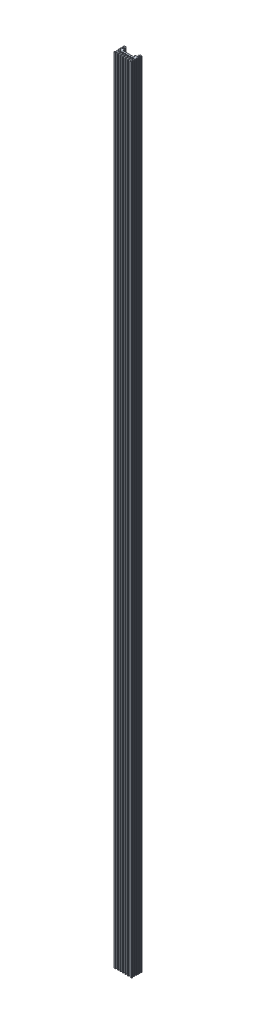
from build123d import *

# Parameters (mm, degrees)
SALIENTE_EXTRUIR1_DEPTH = 920


with BuildPart() as part:
    # Croquis1 → Saliente-Extruir1 (new body)
    with BuildSketch(Plane(origin=(0, 0, 0), x_dir=(1, 0, 0), z_dir=(0, 1, 0))):
        with BuildLine():
            Line((-12.795818551, 0), (-12.344725918, 0))
            ThreePointArc((-12.344725918, 0), (-12.164799993, 0.074527758), (-12.090272234, 0.254453684))
            Line((-12.090272234, 0.254453684), (-12.090272234, 4.705546316))
            ThreePointArc((-12.090272234, 4.705546316), (-12.015744476, 4.885472242), (-11.835818551, 4.96))
            Line((-11.835818551, 4.96), (-10.424725918, 4.96))
            ThreePointArc((-10.424725918, 4.96), (-10.244799993, 4.885472242), (-10.170272234, 4.705546316))
            Line((-10.170272234, 4.705546316), (-10.170272234, 0.254453684))
            ThreePointArc((-10.170272234, 0.254453684), (-10.095744476, 0.074527758), (-9.915818551, 0))
            Line((-9.915818551, 0), (-9.464725918, 0))
            ThreePointArc((-9.464725918, 0), (-9.284799993, 0.074527758), (-9.210272234, 0.254453684))
            Line((-9.210272234, 0.254453684), (-9.210272234, 4.705546316))
            ThreePointArc((-9.210272234, 4.705546316), (-9.135744476, 4.885472242), (-8.955818551, 4.96))
            Line((-8.955818551, 4.96), (-7.544725918, 4.96))
            ThreePointArc((-7.544725918, 4.96), (-7.364799993, 4.885472242), (-7.290272234, 4.705546316))
            Line((-7.290272234, 4.705546316), (-7.290272234, 0.254453684))
            ThreePointArc((-7.290272234, 0.254453684), (-7.215744476, 0.074527758), (-7.035818551, 0))
            Line((-7.035818551, 0), (-6.584725918, 0))
            ThreePointArc((-6.584725918, 0), (-6.404799993, 0.074527758), (-6.330272234, 0.254453684))
            Line((-6.330272234, 0.254453684), (-6.330272234, 4.705546316))
            ThreePointArc((-6.330272234, 4.705546316), (-6.255744476, 4.885472242), (-6.075818551, 4.96))
            Line((-6.075818551, 4.96), (-4.664725918, 4.96))
            ThreePointArc((-4.664725918, 4.96), (-4.484799993, 4.885472242), (-4.410272234, 4.705546316))
            Line((-4.410272234, 4.705546316), (-4.410272234, 0.254453684))
            ThreePointArc((-4.410272234, 0.254453684), (-4.335744476, 0.074527758), (-4.155818551, 0))
            Line((-4.155818551, 0), (-3.704725918, 0))
            ThreePointArc((-3.704725918, 0), (-3.524799993, 0.074527758), (-3.450272234, 0.254453684))
            Line((-3.450272234, 0.254453684), (-3.450272234, 4.705546316))
            ThreePointArc((-3.450272234, 4.705546316), (-3.375744476, 4.885472242), (-3.195818551, 4.96))
            Line((-3.195818551, 4.96), (-1.784725918, 4.96))
            ThreePointArc((-1.784725918, 4.96), (-1.604799993, 4.885472242), (-1.530272234, 4.705546316))
            Line((-1.530272234, 4.705546316), (-1.530272234, 0.254453684))
            ThreePointArc((-1.530272234, 0.254453684), (-1.455744476, 0.074527758), (-1.275818551, 0))
            Line((-1.275818551, 0), (-0.824725918, 0))
            ThreePointArc((-0.824725918, 0), (-0.644799993, 0.074527758), (-0.570272234, 0.254453684))
            Line((-0.570272234, 0.254453684), (-0.570272234, 4.705546316))
            ThreePointArc((-0.570272234, 4.705546316), (-0.495744476, 4.885472242), (-0.315818551, 4.96))
            Line((-0.315818551, 4.96), (1.095274082, 4.96))
            ThreePointArc((1.095274082, 4.96), (1.275200007, 4.885472242), (1.349727766, 4.705546316))
            Line((1.349727766, 4.705546316), (1.349727766, 0.3))
            ThreePointArc((1.349727766, 0.3), (1.437595731, 0.087867966), (1.649727766, 0))
            Line((1.649727766, 0), (3.175274082, 0))
            ThreePointArc((3.175274082, 0), (3.355200007, 0.074527758), (3.429727766, 0.254453684))
            Line((3.429727766, 0.254453684), (3.429727766, 0.705546316))
            ThreePointArc((3.429727766, 0.705546316), (3.355200007, 0.885472242), (3.175274082, 0.96))
            Line((3.175274082, 0.96), (2.724181449, 0.96))
            ThreePointArc((2.724181449, 0.96), (2.544255524, 1.034527758), (2.469727766, 1.214453684))
            Line((2.469727766, 1.214453684), (2.469727766, 2.305546316))
            ThreePointArc((2.469727766, 2.305546316), (2.544255524, 2.485472242), (2.724181449, 2.56))
            Line((2.724181449, 2.56), (3.175274082, 2.56))
            ThreePointArc((3.175274082, 2.56), (3.355200007, 2.634527758), (3.429727766, 2.814453684))
            Line((3.429727766, 2.814453684), (3.429727766, 3.265546316))
            ThreePointArc((3.429727766, 3.265546316), (3.355200007, 3.445472242), (3.175274082, 3.52))
            Line((3.175274082, 3.52), (2.724181449, 3.52))
            ThreePointArc((2.724181449, 3.52), (2.544255524, 3.594527758), (2.469727766, 3.774453684))
            Line((2.469727766, 3.774453684), (2.469727766, 4.705546316))
            ThreePointArc((2.469727766, 4.705546316), (2.544255524, 4.885472242), (2.724181449, 4.96))
            Line((2.724181449, 4.96), (3.175274082, 4.96))
            ThreePointArc((3.175274082, 4.96), (3.355200007, 5.034527758), (3.429727766, 5.214453684))
            Line((3.429727766, 5.214453684), (3.429727766, 5.799468719))
            ThreePointArc((3.429727766, 5.799468719), (3.397938251, 5.922624495), (3.310512788, 6.015007972))
            ThreePointArc((3.310512788, 6.015007972), (2.8735065, 6.114529702), (2.469727766, 5.92))
            ThreePointArc((2.469727766, 5.92), (1.869727766, 6.52), (2.469727766, 7.12))
            ThreePointArc((2.469727766, 7.12), (2.902206504, 6.922842906), (3.357982704, 7.057664398))
            ThreePointArc((3.357982704, 7.057664398), (3.410795902, 7.121117035), (3.429727766, 7.201472841))
            Line((3.429727766, 7.201472841), (3.429727766, 7.9))
            ThreePointArc((3.429727766, 7.9), (3.377006986, 8.027279221), (3.249727766, 8.08))
            Line((3.249727766, 8.08), (2.011728335, 8.08))
            ThreePointArc((2.011728335, 8.08), (1.884449114, 8.132720779), (1.831728335, 8.26))
            Line((1.831728335, 8.26), (1.831728335, 8.66))
            ThreePointArc((1.831728335, 8.66), (1.884449114, 8.787279221), (2.011728335, 8.84))
            Line((2.011728335, 8.84), (3.249727766, 8.84))
            ThreePointArc((3.249727766, 8.84), (3.377006986, 8.892720779), (3.429727766, 9.02))
            Line((3.429727766, 9.02), (3.429727766, 9.62))
            ThreePointArc((3.429727766, 9.62), (3.377006986, 9.747279221), (3.249727766, 9.8))
            Line((3.249727766, 9.8), (2.011728335, 9.8))
            ThreePointArc((2.011728335, 9.8), (1.884449114, 9.852720779), (1.831728335, 9.98))
            Line((1.831728335, 9.98), (1.831728335, 10.58))
            ThreePointArc((1.831728335, 10.58), (1.884449114, 10.707279221), (2.011728335, 10.76))
            Line((2.011728335, 10.76), (3.249727766, 10.76))
            ThreePointArc((3.249727766, 10.76), (3.377006986, 10.812720779), (3.429727766, 10.94))
            Line((3.429727766, 10.94), (3.429727766, 11.582241708))
            ThreePointArc((3.429727766, 11.582241708), (3.392572396, 11.691765274), (3.296445415, 11.756073411))
            ThreePointArc((3.296445415, 11.756073411), (2.405656106, 11.98423262), (1.509727766, 12.191294507))
            ThreePointArc((1.509727766, 12.191294507), (1.442603785, 11.578123194), (0.927709131, 11.238464272))
            ThreePointArc((0.927709131, 11.238464272), (0.77179227, 11.15317057), (0.709727766, 10.986638048))
            Line((0.709727766, 10.986638048), (0.709727766, 9.904615947))
            ThreePointArc((0.709727766, 9.904615947), (0.77079599, 9.739241399), (0.924688231, 9.653245776))
            ThreePointArc((0.924688231, 9.653245776), (1.337381638, 9.065066234), (0.734940069, 8.673485873))
            ThreePointArc((0.734940069, 8.673485873), (0.706521357, 8.678366223), (0.677732961, 8.68))
            Line((0.677732961, 8.68), (-1.246608635, 8.68))
            ThreePointArc((-1.246608635, 8.68), (-1.369764411, 8.648210485), (-1.462147888, 8.560785023))
            ThreePointArc((-1.462147888, 8.560785023), (-1.565962426, 8.2), (-1.462147888, 7.839214977))
            ThreePointArc((-1.462147888, 7.839214977), (-1.369764411, 7.751789515), (-1.246608635, 7.72))
            Line((-1.246608635, 7.72), (-0.68264527, 7.72))
            ThreePointArc((-0.68264527, 7.72), (-0.568471526, 7.692946917), (-0.478575298, 7.617540144))
            ThreePointArc((-0.478575298, 7.617540144), (-0.293758965, 7.06), (-0.478575298, 6.502459856))
            ThreePointArc((-0.478575298, 6.502459856), (-0.568471526, 6.427053083), (-0.68264527, 6.4))
            Line((-0.68264527, 6.4), (-12.937899199, 6.4))
            ThreePointArc((-12.937899199, 6.4), (-13.052072943, 6.427053083), (-13.141969171, 6.502459856))
            ThreePointArc((-13.141969171, 6.502459856), (-13.326785504, 7.06), (-13.141969171, 7.617540144))
            ThreePointArc((-13.141969171, 7.617540144), (-13.052072943, 7.692946917), (-12.937899199, 7.72))
            Line((-12.937899199, 7.72), (-12.373935834, 7.72))
            ThreePointArc((-12.373935834, 7.72), (-12.250780058, 7.751789515), (-12.158396581, 7.839214977))
            ThreePointArc((-12.158396581, 7.839214977), (-12.054582043, 8.2), (-12.158396581, 8.560785023))
            ThreePointArc((-12.158396581, 8.560785023), (-12.250780058, 8.648210485), (-12.373935834, 8.68))
            Line((-12.373935834, 8.68), (-14.29827743, 8.68))
            ThreePointArc((-14.29827743, 8.68), (-14.327065826, 8.678366223), (-14.355484538, 8.673485873))
            ThreePointArc((-14.355484538, 8.673485873), (-14.957926107, 9.065066234), (-14.5452327, 9.653245776))
            ThreePointArc((-14.5452327, 9.653245776), (-14.391340458, 9.739241399), (-14.330272234, 9.904615947))
            Line((-14.330272234, 9.904615947), (-14.330272234, 10.986638048))
            ThreePointArc((-14.330272234, 10.986638048), (-14.392336739, 11.15317057), (-14.5482536, 11.238464272))
            ThreePointArc((-14.5482536, 11.238464272), (-15.063148254, 11.578123194), (-15.130272234, 12.191294507))
            ThreePointArc((-15.130272234, 12.191294507), (-16.026200575, 11.98423262), (-16.916989884, 11.756073411))
            ThreePointArc((-16.916989884, 11.756073411), (-17.013116865, 11.691765274), (-17.050272234, 11.582241708))
            Line((-17.050272234, 11.582241708), (-17.050272234, 10.94))
            ThreePointArc((-17.050272234, 10.94), (-16.997551455, 10.812720779), (-16.870272234, 10.76))
            Line((-16.870272234, 10.76), (-15.632272804, 10.76))
            ThreePointArc((-15.632272804, 10.76), (-15.504993583, 10.707279221), (-15.452272804, 10.58))
            Line((-15.452272804, 10.58), (-15.452272804, 9.98))
            ThreePointArc((-15.452272804, 9.98), (-15.504993583, 9.852720779), (-15.632272804, 9.8))
            Line((-15.632272804, 9.8), (-16.870272234, 9.8))
            ThreePointArc((-16.870272234, 9.8), (-16.997551455, 9.747279221), (-17.050272234, 9.62))
            Line((-17.050272234, 9.62), (-17.050272234, 9.02))
            ThreePointArc((-17.050272234, 9.02), (-16.997551455, 8.892720779), (-16.870272234, 8.84))
            Line((-16.870272234, 8.84), (-15.632272804, 8.84))
            ThreePointArc((-15.632272804, 8.84), (-15.504993583, 8.787279221), (-15.452272804, 8.66))
            Line((-15.452272804, 8.66), (-15.452272804, 8.26))
            ThreePointArc((-15.452272804, 8.26), (-15.504993583, 8.132720779), (-15.632272804, 8.08))
            Line((-15.632272804, 8.08), (-16.870272234, 8.08))
            ThreePointArc((-16.870272234, 8.08), (-16.997551455, 8.027279221), (-17.050272234, 7.9))
            Line((-17.050272234, 7.9), (-17.050272234, 7.201472841))
            ThreePointArc((-17.050272234, 7.201472841), (-17.03134037, 7.121117035), (-16.978527173, 7.057664398))
            ThreePointArc((-16.978527173, 7.057664398), (-16.522750973, 6.922842906), (-16.090272234, 7.12))
            ThreePointArc((-16.090272234, 7.12), (-15.490272234, 6.52), (-16.090272234, 5.92))
            ThreePointArc((-16.090272234, 5.92), (-16.494050968, 6.114529702), (-16.931057257, 6.015007972))
            ThreePointArc((-16.931057257, 6.015007972), (-17.018482719, 5.922624495), (-17.050272234, 5.799468719))
            Line((-17.050272234, 5.799468719), (-17.050272234, 5.214453684))
            ThreePointArc((-17.050272234, 5.214453684), (-16.975744476, 5.034527758), (-16.795818551, 4.96))
            Line((-16.795818551, 4.96), (-16.344725918, 4.96))
            ThreePointArc((-16.344725918, 4.96), (-16.164799993, 4.885472242), (-16.090272234, 4.705546316))
            Line((-16.090272234, 4.705546316), (-16.090272234, 3.774453684))
            ThreePointArc((-16.090272234, 3.774453684), (-16.164799993, 3.594527758), (-16.344725918, 3.52))
            Line((-16.344725918, 3.52), (-16.795818551, 3.52))
            ThreePointArc((-16.795818551, 3.52), (-16.975744476, 3.445472242), (-17.050272234, 3.265546316))
            Line((-17.050272234, 3.265546316), (-17.050272234, 2.814453684))
            ThreePointArc((-17.050272234, 2.814453684), (-16.975744476, 2.634527758), (-16.795818551, 2.56))
            Line((-16.795818551, 2.56), (-16.344725918, 2.56))
            ThreePointArc((-16.344725918, 2.56), (-16.164799993, 2.485472242), (-16.090272234, 2.305546316))
            Line((-16.090272234, 2.305546316), (-16.090272234, 1.214453684))
            ThreePointArc((-16.090272234, 1.214453684), (-16.164799993, 1.034527758), (-16.344725918, 0.96))
            Line((-16.344725918, 0.96), (-16.795818551, 0.96))
            ThreePointArc((-16.795818551, 0.96), (-16.975744476, 0.885472242), (-17.050272234, 0.705546316))
            Line((-17.050272234, 0.705546316), (-17.050272234, 0.254453684))
            ThreePointArc((-17.050272234, 0.254453684), (-16.975744476, 0.074527758), (-16.795818551, 0))
            Line((-16.795818551, 0), (-15.270272234, 0))
            ThreePointArc((-15.270272234, 0), (-15.0581402, 0.087867966), (-14.970272234, 0.3))
            Line((-14.970272234, 0.3), (-14.970272234, 4.705546316))
            ThreePointArc((-14.970272234, 4.705546316), (-14.895744476, 4.885472242), (-14.715818551, 4.96))
            Line((-14.715818551, 4.96), (-13.304725918, 4.96))
            ThreePointArc((-13.304725918, 4.96), (-13.124799993, 4.885472242), (-13.050272234, 4.705546316))
            Line((-13.050272234, 4.705546316), (-13.050272234, 0.254453684))
            ThreePointArc((-13.050272234, 0.254453684), (-12.975744476, 0.074527758), (-12.795818551, 0))
        make_face()
    extrude(amount=SALIENTE_EXTRUIR1_DEPTH)


solid = part.part
